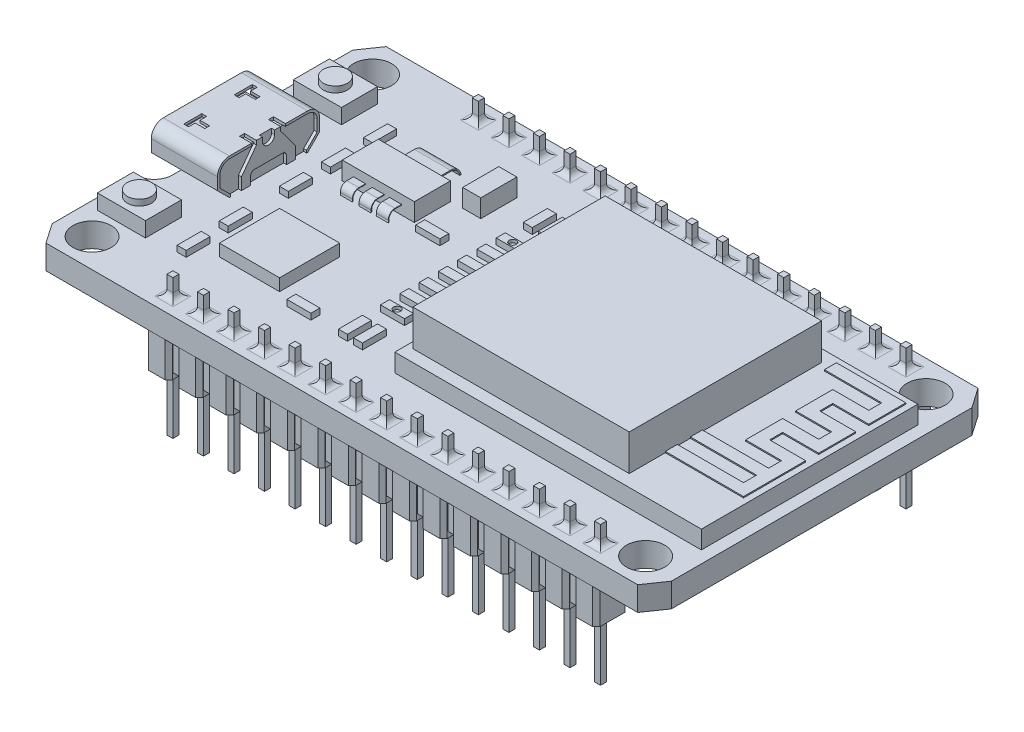
from build123d import *

# Parameters (mm, degrees)
CROQUIS1_W                = 51.5
CROQUIS1_H                = 28.3
SALIENTE_EXTRUIR1_DEPTH   = 2
CROQUIS2_R                = 1.5875
CORTAR_EXTRUIR1_DEPTH     = 2
CROQUIS13_OUTSIDE_W       = 65.26
CROQUIS13_OUTSIDE_H       = 42.06
CORTAR_EXTRUIR2_DEPTH     = 3
CROQUIS3_W                = 25.5
CROQUIS3_H                = 18
SALIENTE_EXTRUIR2_DEPTH   = 1.5
CROQUIS4_W                = 18
CROQUIS4_H                = 16
SALIENTE_EXTRUIR3_DEPTH   = 3
SALIENTE_EXTRUIR4_START   = -10
CROQUIS5_W                = 0.5
CROQUIS5_H                = 0.5
SALIENTE_EXTRUIR4_DEPTH   = 11.5875
CROQUIS6_W                = 2
CROQUIS6_H                = 2.7
SALIENTE_EXTRUIR5_DEPTH   = 3
CHAFL_N1_SIZE             = 0.3
REDONDEO2_R               = 0.5
MATRIZL1_COUNT            = 15
MATRIZL1_PITCH            = 2.54
CHAFL_N1_OF_MATRIZL1_SIZE = 0.3
REDONDEO2_OF_MATRIZL1_R   = 0.5
CROQUIS8_W                = 37.56
CROQUIS8_H                = 2
SALIENTE_EXTRUIR6_DEPTH   = 2.5
CROQUIS12_W               = 5.5
CROQUIS12_H               = 8.5
SALIENTE_EXTRUIR9_DEPTH   = 3
REDONDEO1_R               = 1
CORTAR_EXTRUIR3_DEPTH     = 6
CORTAR_EXTRUIR4_DEPTH     = 4
CORTAR_EXTRUIR5_DEPTH     = 0.25
CROQUIS17_W               = 1
CROQUIS17_H               = 0.411065286
CORTAR_EXTRUIR6_DEPTH     = 0.25
CROQUIS18_W               = 5.68961293
CROQUIS18_H               = 0.758953995
SALIENTE_EXTRUIR10_DEPTH  = 3.25
CROQUIS19_W               = 4
CROQUIS19_H               = 3
SALIENTE_EXTRUIR11_DEPTH  = 1.25
CROQUIS22_R               = 1
SALIENTE_EXTRUIR13_DEPTH  = 0.5
CROQUIS23_W               = 0.75
CROQUIS23_H               = 2
CROQUIS23_W_2             = 2
CROQUIS23_H_2             = 0.75
SALIENTE_EXTRUIR14_DEPTH  = 0.5
CROQUIS26_W               = 5
CROQUIS26_H               = 5
SALIENTE_EXTRUIR15_DEPTH  = 1
CROQUIS27_W               = 1.5
CROQUIS27_H               = 3
SALIENTE_EXTRUIR16_DEPTH  = 1.5
CROQUIS28_W               = 6
CROQUIS28_H               = 3
SALIENTE_EXTRUIR17_DEPTH  = 1.5
SALIENTE_EXTRUIR18_DEPTH  = 0.1
CROQUIS31_R               = 0.3
CORTAR_EXTRUIR7_DEPTH     = 0.25
CROQUIS33_W               = 3
CROQUIS33_H               = 0.1
CROQUIS35_W               = 1
CROQUIS35_H               = 0.05
CORTAR_EXTRUIR8_DEPTH     = 0.5


with BuildPart() as part:
    # Croquis1 → Saliente-Extruir1 (new body)
    with BuildSketch(Plane(origin=(0, 0, 0), x_dir=(1, 0, 0), z_dir=(0, 1, 0))):
        Rectangle(CROQUIS1_W, CROQUIS1_H)
    extrude(amount=SALIENTE_EXTRUIR1_DEPTH)

    # Croquis2 → Cortar-Extruir1 (cut)
    with BuildSketch(Plane(origin=(0, 2, 0), x_dir=(1, 0, 0), z_dir=(0, 1, 0))):
        with Locations((-23.1625, 11.5625)):
            Circle(CROQUIS2_R)
        with Locations((22.875, 11.5625)):
            Circle(CROQUIS2_R)
        with Locations((-23.1625, -11.7625)):
            Circle(CROQUIS2_R)
        with Locations((22.875, -11.7625)):
            Circle(CROQUIS2_R)
    extrude(amount=-CORTAR_EXTRUIR1_DEPTH, mode=Mode.SUBTRACT)

    # Croquis13 outside → Cortar-Extruir2 (cut)
    with BuildSketch(Plane(origin=(0, 2, 0), x_dir=(1, 0, 0), z_dir=(0, 1, 0))):
        Rectangle(CROQUIS13_OUTSIDE_W, CROQUIS13_OUTSIDE_H)
        with BuildLine():
            Line((25.75, 12.5), (25.75, -12.5))
            Line((25.75, -12.5), (24.60625, -14.15))
            Line((24.60625, -14.15), (-24.60625, -14.15))
            Line((-24.60625, -14.15), (-25.75, -12.5))
            Line((-25.75, -12.5), (-25.75, -5.5))
            ThreePointArc((-25.75, -5.5), (-24.689339828, -5.060660172), (-24.25, -4))
            Line((-24.25, -4), (-24.25, 4))
            ThreePointArc((-24.25, 4), (-24.689339828, 5.060660172), (-25.75, 5.5))
            Line((-25.75, 5.5), (-25.75, 12.5))
            Line((-25.75, 12.5), (-24.60625, 14.15))
            Line((-24.60625, 14.15), (24.60625, 14.15))
            Line((24.60625, 14.15), (25.75, 12.5))
        make_face(mode=Mode.SUBTRACT)
    extrude(amount=-CORTAR_EXTRUIR2_DEPTH, mode=Mode.SUBTRACT)

    # Croquis3 → Saliente-Extruir2 (add)
    with BuildSketch(Plane(origin=(0, 2, 0), x_dir=(1, 0, 0), z_dir=(0, 1, 0))):
        with Locations((12, 0)):
            Rectangle(CROQUIS3_W, CROQUIS3_H)
    extrude(amount=SALIENTE_EXTRUIR2_DEPTH)

    # Croquis4 → Saliente-Extruir3 (add)
    with BuildSketch(Plane(origin=(0, 3.5, 0), x_dir=(1, 0, 0), z_dir=(0, 1, 0))):
        with Locations((8.75, 0)):
            Rectangle(CROQUIS4_W, CROQUIS4_H)
    extrude(amount=SALIENTE_EXTRUIR3_DEPTH)

    # Croquis5 → Saliente-Extruir4 (add)
    with BuildSketch(Plane(origin=(0, 2, 0), x_dir=(1, 0, 0), z_dir=(0, 1, 0)).offset(SALIENTE_EXTRUIR4_START)):
        with Locations((-15.5, 12.7)):
            Rectangle(CROQUIS5_W, CROQUIS5_H)
        with Locations((-15.5, -12.7)):
            Rectangle(CROQUIS5_W, CROQUIS5_H)
    saliente_extruir4 = extrude(amount=SALIENTE_EXTRUIR4_DEPTH)

    # Croquis6 → Saliente-Extruir5 (add)
    with BuildSketch(Plane.XZ):
        with Locations((-15.5, -12.7)):
            Rectangle(CROQUIS6_W, CROQUIS6_H)
        with Locations((-15.5, 12.7)):
            Rectangle(CROQUIS6_W, CROQUIS6_H)
    saliente_extruir5 = extrude(amount=SALIENTE_EXTRUIR5_DEPTH)

    # Chaflán1
    chafl_n1_edges = [part.edges().sort_by_distance(p)[0] for p in [
        (-14.5, -1.5, -14.05),
        (-14.5, -1.5, -11.35),
        (-16.5, -1.5, -11.35),
        (-16.5, -1.5, -14.05),
        (-16.5, -1.5, 14.05),
        (-16.5, -1.5, 11.35),
        (-14.5, -1.5, 11.35),
        (-14.5, -1.5, 14.05),
    ]]
    chamfer(chafl_n1_edges, length=CHAFL_N1_SIZE)

    # Redondeo2
    redondeo2_edges = [part.edges().sort_by_distance(p)[0] for p in [
        (-15.75, 2, 12.7),
        (-15.5, 2, 12.95),
        (-15.25, 2, 12.7),
        (-15.5, 2, 12.45),
        (-15.75, 2, -12.7),
        (-15.5, 2, -12.45),
        (-15.25, 2, -12.7),
        (-15.5, 2, -12.95),
    ]]
    fillet(redondeo2_edges, radius=REDONDEO2_R)

    # MatrizL1: Saliente-Extruir4, Saliente-Extruir5 ×15
    with Locations(*[(i * MATRIZL1_PITCH, 0, 0) for i in range(1, MATRIZL1_COUNT)]):
        add(saliente_extruir4)
        add(saliente_extruir5)

    # Chaflán1 of MatrizL1
    chafl_n1_of_matrizl1_edges = [part.edges().sort_by_distance(p)[0] for p in [
        (-11.96, -1.5, -14.05),
        (-11.96, -1.5, -11.35),
        (-13.96, -1.5, -11.35),
        (-13.96, -1.5, -14.05),
        (-13.96, -1.5, 14.05),
        (-13.96, -1.5, 11.35),
        (-11.96, -1.5, 11.35),
        (-11.96, -1.5, 14.05),
        (-9.42, -1.5, -14.05),
        (-9.42, -1.5, -11.35),
        (-11.42, -1.5, -11.35),
        (-11.42, -1.5, -14.05),
        (-11.42, -1.5, 14.05),
        (-11.42, -1.5, 11.35),
        (-9.42, -1.5, 11.35),
        (-9.42, -1.5, 14.05),
        (-6.88, -1.5, -14.05),
        (-6.88, -1.5, -11.35),
        (-8.88, -1.5, -11.35),
        (-8.88, -1.5, -14.05),
        (-8.88, -1.5, 14.05),
        (-8.88, -1.5, 11.35),
        (-6.88, -1.5, 11.35),
        (-6.88, -1.5, 14.05),
        (-4.34, -1.5, -14.05),
        (-4.34, -1.5, -11.35),
        (-6.34, -1.5, -11.35),
        (-6.34, -1.5, -14.05),
        (-6.34, -1.5, 14.05),
        (-6.34, -1.5, 11.35),
        (-4.34, -1.5, 11.35),
        (-4.34, -1.5, 14.05),
        (-1.8, -1.5, -14.05),
        (-1.8, -1.5, -11.35),
        (-3.8, -1.5, -11.35),
        (-3.8, -1.5, -14.05),
        (-3.8, -1.5, 14.05),
        (-3.8, -1.5, 11.35),
        (-1.8, -1.5, 11.35),
        (-1.8, -1.5, 14.05),
        (0.74, -1.5, -14.05),
        (0.74, -1.5, -11.35),
        (-1.26, -1.5, -11.35),
        (-1.26, -1.5, -14.05),
        (-1.26, -1.5, 14.05),
        (-1.26, -1.5, 11.35),
        (0.74, -1.5, 11.35),
        (0.74, -1.5, 14.05),
        (3.28, -1.5, -14.05),
        (3.28, -1.5, -11.35),
        (1.28, -1.5, -11.35),
        (1.28, -1.5, -14.05),
        (1.28, -1.5, 14.05),
        (1.28, -1.5, 11.35),
        (3.28, -1.5, 11.35),
        (3.28, -1.5, 14.05),
        (5.82, -1.5, -14.05),
        (5.82, -1.5, -11.35),
        (3.82, -1.5, -11.35),
        (3.82, -1.5, -14.05),
        (3.82, -1.5, 14.05),
        (3.82, -1.5, 11.35),
        (5.82, -1.5, 11.35),
        (5.82, -1.5, 14.05),
        (8.36, -1.5, -14.05),
        (8.36, -1.5, -11.35),
        (6.36, -1.5, -11.35),
        (6.36, -1.5, -14.05),
        (6.36, -1.5, 14.05),
        (6.36, -1.5, 11.35),
        (8.36, -1.5, 11.35),
        (8.36, -1.5, 14.05),
        (10.9, -1.5, -14.05),
        (10.9, -1.5, -11.35),
        (8.9, -1.5, -11.35),
        (8.9, -1.5, -14.05),
        (8.9, -1.5, 14.05),
        (8.9, -1.5, 11.35),
        (10.9, -1.5, 11.35),
        (10.9, -1.5, 14.05),
        (13.44, -1.5, -14.05),
        (13.44, -1.5, -11.35),
        (11.44, -1.5, -11.35),
        (11.44, -1.5, -14.05),
        (11.44, -1.5, 14.05),
        (11.44, -1.5, 11.35),
        (13.44, -1.5, 11.35),
        (13.44, -1.5, 14.05),
        (15.98, -1.5, -14.05),
        (15.98, -1.5, -11.35),
        (13.98, -1.5, -11.35),
        (13.98, -1.5, -14.05),
        (13.98, -1.5, 14.05),
        (13.98, -1.5, 11.35),
        (15.98, -1.5, 11.35),
        (15.98, -1.5, 14.05),
        (18.52, -1.5, -14.05),
        (18.52, -1.5, -11.35),
        (16.52, -1.5, -11.35),
        (16.52, -1.5, -14.05),
        (16.52, -1.5, 14.05),
        (16.52, -1.5, 11.35),
        (18.52, -1.5, 11.35),
        (18.52, -1.5, 14.05),
        (21.06, -1.5, -14.05),
        (21.06, -1.5, -11.35),
        (19.06, -1.5, -11.35),
        (19.06, -1.5, -14.05),
        (19.06, -1.5, 14.05),
        (19.06, -1.5, 11.35),
        (21.06, -1.5, 11.35),
        (21.06, -1.5, 14.05),
    ]]
    chamfer(chafl_n1_of_matrizl1_edges, length=CHAFL_N1_OF_MATRIZL1_SIZE)

    # Redondeo2 of MatrizL1
    redondeo2_of_matrizl1_edges = [part.edges().sort_by_distance(p)[0] for p in [
        (-13.21, 2, 12.7),
        (-12.96, 2, 12.95),
        (-12.71, 2, 12.7),
        (-12.96, 2, 12.45),
        (-13.21, 2, -12.7),
        (-12.96, 2, -12.45),
        (-12.71, 2, -12.7),
        (-12.96, 2, -12.95),
        (-10.67, 2, 12.7),
        (-10.42, 2, 12.95),
        (-10.17, 2, 12.7),
        (-10.42, 2, 12.45),
        (-10.67, 2, -12.7),
        (-10.42, 2, -12.45),
        (-10.17, 2, -12.7),
        (-10.42, 2, -12.95),
        (-8.13, 2, 12.7),
        (-7.88, 2, 12.95),
        (-7.63, 2, 12.7),
        (-7.88, 2, 12.45),
        (-8.13, 2, -12.7),
        (-7.88, 2, -12.45),
        (-7.63, 2, -12.7),
        (-7.88, 2, -12.95),
        (-5.59, 2, 12.7),
        (-5.34, 2, 12.95),
        (-5.09, 2, 12.7),
        (-5.34, 2, 12.45),
        (-5.59, 2, -12.7),
        (-5.34, 2, -12.45),
        (-5.09, 2, -12.7),
        (-5.34, 2, -12.95),
        (-3.05, 2, 12.7),
        (-2.8, 2, 12.95),
        (-2.55, 2, 12.7),
        (-2.8, 2, 12.45),
        (-3.05, 2, -12.7),
        (-2.8, 2, -12.45),
        (-2.55, 2, -12.7),
        (-2.8, 2, -12.95),
        (-0.51, 2, 12.7),
        (-0.26, 2, 12.95),
        (-0.01, 2, 12.7),
        (-0.26, 2, 12.45),
        (-0.51, 2, -12.7),
        (-0.26, 2, -12.45),
        (-0.01, 2, -12.7),
        (-0.26, 2, -12.95),
        (2.03, 2, 12.7),
        (2.28, 2, 12.95),
        (2.53, 2, 12.7),
        (2.28, 2, 12.45),
        (2.03, 2, -12.7),
        (2.28, 2, -12.45),
        (2.53, 2, -12.7),
        (2.28, 2, -12.95),
        (4.57, 2, 12.7),
        (4.82, 2, 12.95),
        (5.07, 2, 12.7),
        (4.82, 2, 12.45),
        (4.57, 2, -12.7),
        (4.82, 2, -12.45),
        (5.07, 2, -12.7),
        (4.82, 2, -12.95),
        (7.11, 2, 12.7),
        (7.36, 2, 12.95),
        (7.61, 2, 12.7),
        (7.36, 2, 12.45),
        (7.11, 2, -12.7),
        (7.36, 2, -12.45),
        (7.61, 2, -12.7),
        (7.36, 2, -12.95),
        (9.65, 2, 12.7),
        (9.9, 2, 12.95),
        (10.15, 2, 12.7),
        (9.9, 2, 12.45),
        (9.65, 2, -12.7),
        (9.9, 2, -12.45),
        (10.15, 2, -12.7),
        (9.9, 2, -12.95),
        (12.19, 2, 12.7),
        (12.44, 2, 12.95),
        (12.69, 2, 12.7),
        (12.44, 2, 12.45),
        (12.19, 2, -12.7),
        (12.44, 2, -12.45),
        (12.69, 2, -12.7),
        (12.44, 2, -12.95),
        (14.73, 2, 12.7),
        (14.98, 2, 12.95),
        (15.23, 2, 12.7),
        (14.98, 2, 12.45),
        (14.73, 2, -12.7),
        (14.98, 2, -12.45),
        (15.23, 2, -12.7),
        (14.98, 2, -12.95),
        (17.27, 2, 12.7),
        (17.52, 2, 12.95),
        (17.77, 2, 12.7),
        (17.52, 2, 12.45),
        (17.27, 2, -12.7),
        (17.52, 2, -12.45),
        (17.77, 2, -12.7),
        (17.52, 2, -12.95),
        (19.81, 2, 12.7),
        (20.06, 2, 12.95),
        (20.31, 2, 12.7),
        (20.06, 2, 12.45),
        (19.81, 2, -12.7),
        (20.06, 2, -12.45),
        (20.31, 2, -12.7),
        (20.06, 2, -12.95),
    ]]
    fillet(redondeo2_of_matrizl1_edges, radius=REDONDEO2_OF_MATRIZL1_R)

    # Croquis8 → Saliente-Extruir6 (add)
    with BuildSketch(Plane.XZ):
        with Locations((2.28, -12.7)):
            Rectangle(CROQUIS8_W, CROQUIS8_H)
        with Locations((2.28, 12.7)):
            Rectangle(CROQUIS8_W, CROQUIS8_H)
    extrude(amount=SALIENTE_EXTRUIR6_DEPTH)

    # Croquis12 → Saliente-Extruir9 (add)
    with BuildSketch(Plane(origin=(0, 2, 0), x_dir=(1, 0, 0), z_dir=(0, 1, 0))):
        with Locations((-23, 0)):
            Rectangle(CROQUIS12_W, CROQUIS12_H)
    extrude(amount=SALIENTE_EXTRUIR9_DEPTH)

    # Redondeo1
    redondeo1_edges = [part.edges().sort_by_distance(p)[0] for p in [
        (-23, 5, 4.25),
        (-23, 5, -4.25),
    ]]
    fillet(redondeo1_edges, radius=REDONDEO1_R)

    # Croquis14 → Cortar-Extruir3 (cut)
    with BuildSketch(Plane.ZY.offset(25.75)):
        Polygon((-4.25, 2), (-3.25, 2), (-4.25, 3), align=None)
        Polygon((4.25, 3), (3.25, 2), (4.25, 2), align=None)
    extrude(amount=-CORTAR_EXTRUIR3_DEPTH, mode=Mode.SUBTRACT)

    # Croquis15 → Cortar-Extruir4 (cut)
    with BuildSketch(Plane.ZY.offset(25.75)):
        with BuildLine():
            Line((3.25, 4.8), (-3.25, 4.8))
            ThreePointArc((-3.25, 4.8), (-3.815685425, 4.565685425), (-4.05, 4))
            Line((-4.05, 4), (-4.05, 3.082842712))
            Line((-4.05, 3.082842712), (-3.167157288, 2.2))
            Line((-3.167157288, 2.2), (3.167157288, 2.2))
            Line((3.167157288, 2.2), (4.05, 3.082842712))
            Line((4.05, 3.082842712), (4.05, 4))
            ThreePointArc((4.05, 4), (3.815685425, 4.565685425), (3.25, 4.8))
        make_face()
    extrude(amount=-CORTAR_EXTRUIR4_DEPTH, mode=Mode.SUBTRACT)

    # Croquis16 → Cortar-Extruir5 (cut)
    with BuildSketch(Plane(origin=(-20.25, 0, 0), x_dir=(0, 0, -1), z_dir=(1, 0, 0))):
        Polygon((-1.5, 2.750073012), (-1.5, 2), (1.5, 2), (1.5, 2.750073012), (1.316867325, 2.994339073), (-1.316867325, 2.994339073), align=None)
        with BuildLine():
            Line((-2.25, 3), (-1, 4.667275256))
            Line((-1, 4.667275256), (-1, 5))
            Line((-1, 5), (-1.411065286, 5))
            Line((-1.411065286, 5), (-1.411065286, 4.8))
            Line((-1.411065286, 4.8), (-3.25, 4.8))
            ThreePointArc((-3.25, 4.8), (-3.815685425, 4.565685425), (-4.05, 4))
            Line((-4.05, 4), (-4.05, 3.082842712))
            Line((-4.05, 3.082842712), (-3.167157288, 2.2))
            Line((-3.167157288, 2.2), (-3.167157288, 2))
            Line((-3.167157288, 2), (-2.25, 2))
            Line((-2.25, 2), (-2.25, 3))
        make_face()
        with BuildLine():
            Line((-0.5, 5), (0.5, 5))
            Line((0.5, 5), (0.5, 4.667275256))
            ThreePointArc((0.5, 4.667275256), (0, 4.167275256), (-0.5, 4.667275256))
            Line((-0.5, 4.667275256), (-0.5, 5))
        make_face()
        with BuildLine():
            Line((3.167157288, 2.2), (3.167157288, 2))
            Line((3.167157288, 2), (2.25, 2))
            Line((2.25, 2), (2.25, 3))
            Line((2.25, 3), (1, 4.667275256))
            Line((1, 4.667275256), (1, 5))
            Line((1, 5), (1.411065286, 5))
            Line((1.411065286, 5), (1.411065286, 4.8))
            Line((1.411065286, 4.8), (3.25, 4.8))
            ThreePointArc((3.25, 4.8), (3.815685425, 4.565685425), (4.05, 4))
            Line((4.05, 4), (4.05, 3.082842712))
            Line((4.05, 3.082842712), (3.167157288, 2.2))
        make_face()
    extrude(amount=-CORTAR_EXTRUIR5_DEPTH, mode=Mode.SUBTRACT)

    # Croquis17 → Cortar-Extruir6 (cut)
    with BuildSketch(Plane(origin=(0, 5, 0), x_dir=(1, 0, 0), z_dir=(0, 1, 0))):
        with Locations((-20.75, -1.205532643)):
            Rectangle(CROQUIS17_W, CROQUIS17_H)
        with Locations((-20.75, 1.205532643)):
            Rectangle(CROQUIS17_W, CROQUIS17_H)
    extrude(amount=-CORTAR_EXTRUIR6_DEPTH, mode=Mode.SUBTRACT)

    # Croquis18 → Saliente-Extruir10 (add)
    with BuildSketch(Plane.ZY.offset(21.75)):
        with Locations((0, 3.814056829)):
            Rectangle(CROQUIS18_W, CROQUIS18_H)
    extrude(amount=SALIENTE_EXTRUIR10_DEPTH)

    # Croquis19 → Saliente-Extruir11 (add)
    with BuildSketch(Plane(origin=(0, 2, 0), x_dir=(1, 0, 0), z_dir=(0, 1, 0))):
        with Locations((-22.837294818, -8.15)):
            Rectangle(CROQUIS19_W, CROQUIS19_H)
        with Locations((-22.837294818, 8.15)):
            Rectangle(CROQUIS19_W, CROQUIS19_H)
    extrude(amount=SALIENTE_EXTRUIR11_DEPTH)

    # Croquis22 → Saliente-Extruir13 (add)
    with BuildSketch(Plane(origin=(0, 3.25, 0), x_dir=(1, 0, 0), z_dir=(0, 1, 0))):
        with Locations((-22.837294818, 8.15)):
            Circle(CROQUIS22_R)
        with Locations((-22.837294818, -8.15)):
            Circle(CROQUIS22_R)
    extrude(amount=SALIENTE_EXTRUIR13_DEPTH)

    # Croquis23 → Saliente-Extruir14 (add)
    with BuildSketch(Plane(origin=(0, 2, 0), x_dir=(1, 0, 0), z_dir=(0, 1, 0))):
        with Locations((-18.125, 3.65)):
            Rectangle(CROQUIS23_W, CROQUIS23_H)
        with Locations((-18.125, 7.15)):
            Rectangle(CROQUIS23_W, CROQUIS23_H)
        with Locations((-18.125, 0.15)):
            Rectangle(CROQUIS23_W, CROQUIS23_H)
        with Locations((-18.125, -8.35)):
            Rectangle(CROQUIS23_W, CROQUIS23_H)
        with Locations((-18.125, -4.85)):
            Rectangle(CROQUIS23_W, CROQUIS23_H)
        with Locations((-4.75, 3.208333333)):
            Rectangle(CROQUIS23_W_2, CROQUIS23_H_2)
        with Locations((-4.75, 4.8125)):
            Rectangle(CROQUIS23_W_2, CROQUIS23_H_2)
        with Locations((-4.75, 1.604166667)):
            Rectangle(CROQUIS23_W_2, CROQUIS23_H_2)
        with Locations((-4.75, 0)):
            Rectangle(CROQUIS23_W_2, CROQUIS23_H_2)
        with Locations((-4.75, -1.604166667)):
            Rectangle(CROQUIS23_W_2, CROQUIS23_H_2)
        with Locations((-4.75, -3.208333333)):
            Rectangle(CROQUIS23_W_2, CROQUIS23_H_2)
        with Locations((-4.75, -4.8125)):
            Rectangle(CROQUIS23_W_2, CROQUIS23_H_2)
        with Locations((-4.125, -7.6875)):
            Rectangle(CROQUIS23_W, CROQUIS23_H)
        with Locations((-5.375, -7.6875)):
            Rectangle(CROQUIS23_W, CROQUIS23_H)
        with Locations((-4.125, 7.6875)):
            Rectangle(CROQUIS23_W, CROQUIS23_H)
        with Locations((-5.375, 7.6875)):
            Rectangle(CROQUIS23_W, CROQUIS23_H)
        with Locations((-9.0373377, -8.3125)):
            Rectangle(CROQUIS23_W_2, CROQUIS23_H_2)
        with Locations((-9.0373377, 2.40625)):
            Rectangle(CROQUIS23_W_2, CROQUIS23_H_2)
    extrude(amount=SALIENTE_EXTRUIR14_DEPTH)

    # Croquis26 → Saliente-Extruir15 (add)
    with BuildSketch(Plane(origin=(0, 2, 0), x_dir=(1, 0, 0), z_dir=(0, 1, 0))):
        with Locations((-13.89366885, -5.4375)):
            Rectangle(CROQUIS26_W, CROQUIS26_H)
    extrude(amount=SALIENTE_EXTRUIR15_DEPTH)

    # Croquis27 → Saliente-Extruir16 (add)
    with BuildSketch(Plane(origin=(0, 2, 0), x_dir=(1, 0, 0), z_dir=(0, 1, 0))):
        with Locations((-9.0373377, 7.1875)):
            Rectangle(CROQUIS27_W, CROQUIS27_H)
    extrude(amount=SALIENTE_EXTRUIR16_DEPTH)

    # Croquis28 → Saliente-Extruir17 (add)
    with BuildSketch(Plane(origin=(0, 2, 0), x_dir=(1, 0, 0), z_dir=(0, 1, 0))):
        with Locations((-13.76866885, 4.15)):
            Rectangle(CROQUIS28_W, CROQUIS28_H)
    extrude(amount=SALIENTE_EXTRUIR17_DEPTH)

    # Croquis30 → Saliente-Extruir18 (add)
    with BuildSketch(Plane(origin=(0, 3.5, 0), x_dir=(1, 0, 0), z_dir=(0, 1, 0))):
        Polygon((18.479746063, 7.5), (23.254418174, 7.5), (23.254418174, 6.416666667), (20.258739977, 6.416666667), (20.258739977, 3.333333333), (23.254418174, 3.333333333), (23.254418174, 2.25), (20.258739977, 2.25), (20.258739977, -0.833333333), (23.254418174, -0.833333333), (23.254418174, -1.916666667), (17.75, -1.916666667), (17.75, -2.916666667), (23.254418174, -2.916666667), (23.254418174, -4), (17.75, -4), (17.75, -5), (24.254418174, -5), (24.254418174, -2.416666667), (24.254418174, 0.166666667), (21.258739977, 0.166666667), (21.258739977, 1.25), (24.254418174, 1.25), (24.254418174, 4.333333333), (21.258739977, 4.333333333), (21.258739977, 5.416666667), (24.254418174, 5.416666667), (24.254418174, 8.5), (18.479746063, 8.5), align=None)
    extrude(amount=SALIENTE_EXTRUIR18_DEPTH)

    # Croquis31 → Cortar-Extruir7 (cut)
    with BuildSketch(Plane(origin=(0, 2.5, 0), x_dir=(1, 0, 0), z_dir=(0, 1, 0))):
        with Locations((-4.75, 4.8125)):
            Circle(CROQUIS31_R)
        with Locations((-4.75, -4.8125)):
            Circle(CROQUIS31_R)
    extrude(amount=-CORTAR_EXTRUIR7_DEPTH, mode=Mode.SUBTRACT)

    # Barrer1: sweep along a path in Croquis32
    with BuildLine(Plane.ZY.offset(13.76866885)) as barrer1_path:
        Line((-5.65, 2.75), (-7.153654608, 2.75))
        ThreePointArc((-7.153654608, 2.75), (-7.770370245, 2.494548019), (-8.025822226, 1.877832382))
    # Croquis33 → Barrer1 (sweep)
    with BuildSketch(Plane(origin=(0, 0, -5.65), x_dir=(-1, 0, 0), z_dir=(0, 0, -1))):
        with Locations((13.76866885, 2.714914663)):
            Rectangle(CROQUIS33_W, CROQUIS33_H)
    sweep(path=barrer1_path.line)

    # Barrer2: sweep along a path in Croquis34
    with BuildLine(Plane.ZY.offset(13.76866885)) as barrer2_path:
        Line((-2.65, 2.75), (-2.095942459, 2.75))
        ThreePointArc((-2.095942459, 2.75), (-1.707871888, 2.575411266), (-1.581097256, 2.16919927))
        ThreePointArc((-1.581097256, 2.16919927), (-1.436021267, 1.850627734), (-1.086379703, 1.833726789))
    # Croquis35 → Barrer2 (sweep)
    with BuildSketch(Plane.XY.offset(-2.65)):
        with Locations((-13.76866885, 2.748535406)):
            Rectangle(CROQUIS35_W, CROQUIS35_H)
        with Locations((-15.33116885, 2.736035406)):
            Rectangle(CROQUIS35_W, CROQUIS35_H)
        with Locations((-12.33116885, 2.748535406)):
            Rectangle(CROQUIS35_W, CROQUIS35_H)
    sweep(path=barrer2_path.line)

    # Croquis36 → Cortar-Extruir8 (cut)
    with BuildSketch(Plane(origin=(0, 5, 0), x_dir=(1, 0, 0), z_dir=(0, 1, 0))):
        Polygon((-24.05, -2.3), (-23.25, -2.3), (-23.25, -1.9), (-24.05, -1.9), (-24.05, -1.35), (-24.45, -1.35), (-24.45, -2.85), (-24.05, -2.85), align=None)
        Polygon((-24.05, 1.35), (-24.05, 1.9), (-23.25, 1.9), (-23.25, 2.3), (-24.05, 2.3), (-24.05, 2.85), (-24.45, 2.85), (-24.45, 1.35), align=None)
    extrude(amount=-CORTAR_EXTRUIR8_DEPTH, mode=Mode.SUBTRACT)


solid = part.part
